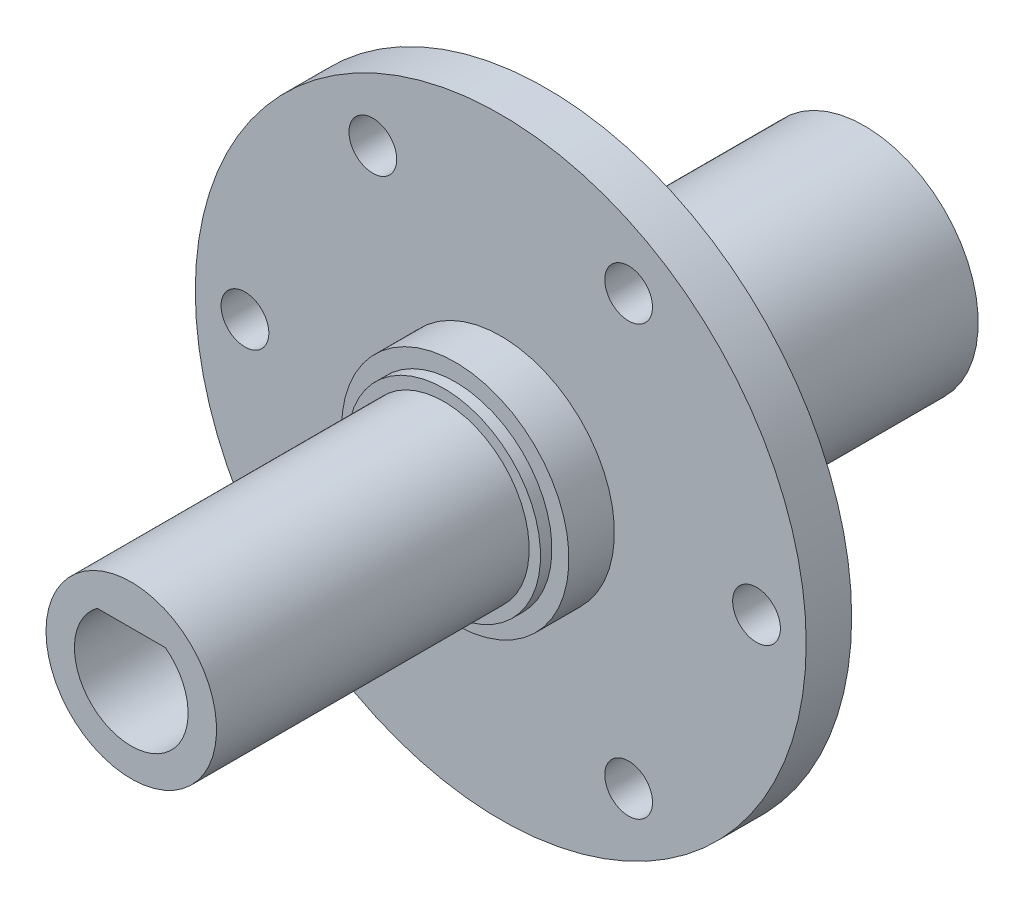
from build123d import *

# Parameters (mm, degrees)
CUT_EXTRUDE_1_DEPTH = 13.4
SKETCH_4_R          = 2.1
CUT_EXTRUDE_2_DEPTH = 13.4


with BuildPart() as part:
    # 草图2 → 旋转1 (revolve)
    with BuildSketch(Plane(origin=(0, 0, 0), x_dir=(1, 0, 0), z_dir=(0, 1, 0))):
        Polygon((-21.742218247, 43.984257603), (-18.742218247, 43.984257603), (-18.742218247, 23.034257603), (-11.742218247, 18.979304476), (-11.742218247, -20.515742397), (-19.242218247, -20.515742397), (-19.242218247, 6.984257603), (-20.242218247, 6.984257603), (-20.242218247, 7.984257603), (-21.742218247, 7.984257603), (-21.742218247, 11.984257603), (-38.612218247, 11.984257603), (-38.612218247, 15.984257603), (-21.742218247, 15.984257603), align=None)
    revolve(axis=Axis((-11.742218247, 0, -18.979304476), (0, 0, 1)))

    # 草图3 → 切除-拉伸1 (cut)
    with BuildSketch(Plane.XY.offset(20.515742397)):
        with BuildLine():
            Line((-11.742218247, 4), (-14.742218247, 4))
            ThreePointArc((-14.742218247, 4), (-11.742218247, -5), (-8.742218247, 4))
            Line((-8.742218247, 4), (-11.742218247, 4))
        make_face()
    extrude(amount=-CUT_EXTRUDE_1_DEPTH, mode=Mode.SUBTRACT)

    # 草图4 → 切除-拉伸2 (cut)
    with BuildSketch(Plane.XY.offset(-11.984257603)):
        with Locations((-0.492218247, -18.86)):
            Circle(SKETCH_4_R)
        with Locations((10.757781753, 0)):
            Circle(SKETCH_4_R)
        with Locations((-22.992218247, -18.86)):
            Circle(SKETCH_4_R)
        with Locations((-34.242218247, 0)):
            Circle(SKETCH_4_R)
        with Locations((-22.992218247, 18.86)):
            Circle(SKETCH_4_R)
        with Locations((-0.492218247, 18.86)):
            Circle(SKETCH_4_R)
    extrude(amount=-CUT_EXTRUDE_2_DEPTH, mode=Mode.SUBTRACT)


solid = part.part
